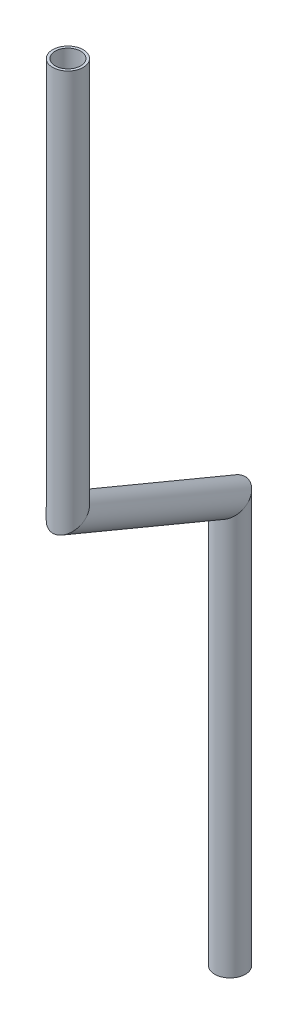
from build123d import *

# Parameters (mm, degrees)
SKETCH1_R                 = 6.35
SKETCH1_R_2               = 5.2832
PIPE_0_5_SCH_40_1_DEPTH   = 169.896432715
SKETCH1_ON_SEGMENT_2_R    = 6.35
SKETCH1_ON_SEGMENT_2_R_2  = 5.2832
PIPE_0_5_SCH_40_1_2_DEPTH = 90.194153874
SKETCH1_ON_SEGMENT_3_R    = 6.35
SKETCH1_ON_SEGMENT_3_R_2  = 5.2832
PIPE_0_5_SCH_40_1_3_DEPTH = 174.981068719


with BuildPart() as part:
    # Sketch1 → Pipe 0.5 SCH 40(1) (new body)
    with BuildSketch(Plane(origin=(-822.204533178, -35.658828401, 344.151093016), x_dir=(1, 0, 0), z_dir=(0, -1, 0))):
        Circle(SKETCH1_R)
        Circle(SKETCH1_R_2, mode=Mode.SUBTRACT)
    extrude(amount=PIPE_0_5_SCH_40_1_DEPTH)

    # Pipe 0.5 SCH 40(1) mitre 1
    split(bisect_by=Plane(origin=(-822.204533178, -198.688949127, 344.151093016), x_dir=(-0.999668627, 0.025741717, 0), z_dir=(0.021558105, 0.837199865, 0.546471989)), keep=Keep.TOP)


with BuildPart() as body_2:
    # Sketch1 on segment 2 (carried to segment 2) → Pipe 0.5 SCH 40_1 2 (new body)
    with BuildSketch(Plane(origin=(-821.956680698, -195.930015343, 350.433854657), x_dir=(0.999070496, -0.036096886, -0.023561801), z_dir=(-0.036096886, -0.401807228, -0.91501255))):
        Circle(SKETCH1_ON_SEGMENT_2_R)
        Circle(SKETCH1_ON_SEGMENT_2_R_2, mode=Mode.SUBTRACT)
    extrude(amount=PIPE_0_5_SCH_40_1_2_DEPTH)

    # Pipe 0.5 SCH 40_1 2 mitre 1
    split(bisect_by=Plane(origin=(-822.204533178, -198.688949127, 344.151093016), x_dir=(0.999668627, -0.025741717, 0), z_dir=(-0.021558105, -0.837199865, -0.546471989)), keep=Keep.TOP)

    # Pipe 0.5 SCH 40_1 2 mitre 2
    split(bisect_by=Plane(origin=(-824.964556297, -229.411744477, 274.187833569), x_dir=(-0.999668627, 0.025741717, 0), z_dir=(0.021558105, 0.837199865, 0.546471989)), keep=Keep.TOP)


with BuildPart() as body_3:
    # Sketch1 on segment 3 (carried to segment 3) → Pipe 0.5 SCH 40_1 3 (new body)
    with BuildSketch(Plane(origin=(-824.964556297, -222.545432488, 274.187833569), x_dir=(1, 0, 0), z_dir=(0, -1, 0))):
        Circle(SKETCH1_ON_SEGMENT_3_R)
        Circle(SKETCH1_ON_SEGMENT_3_R_2, mode=Mode.SUBTRACT)
    extrude(amount=PIPE_0_5_SCH_40_1_3_DEPTH)

    # Pipe 0.5 SCH 40_1 3 mitre 1
    split(bisect_by=Plane(origin=(-824.964556297, -229.411744477, 274.187833569), x_dir=(0.999668627, -0.025741717, 0), z_dir=(-0.021558105, -0.837199865, -0.546471989)), keep=Keep.TOP)


solid = Compound([part.part, body_2.part, body_3.part])
